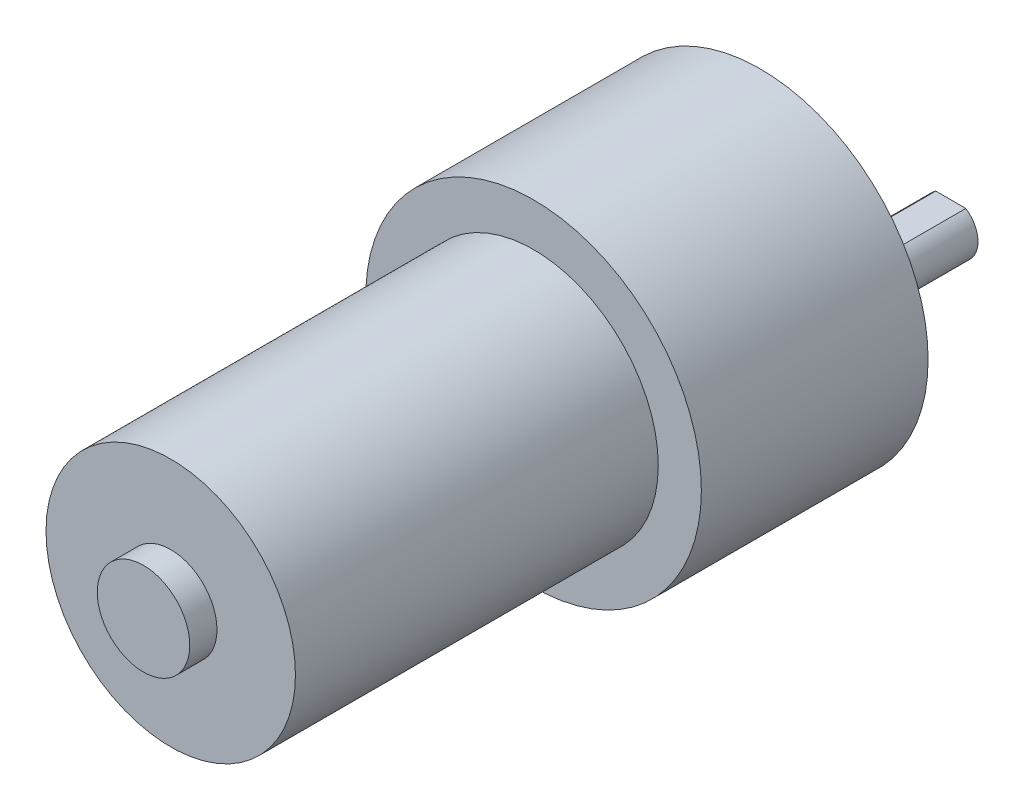
from build123d import *

# Parameters (mm, degrees)
SKETCH_1_R          = 18.5
EXTRUDE_1_DEPTH     = 25
SKETCH_3_R          = 13.75
EXTRUDE_2_DEPTH     = 40
SKETCH_4_R          = 1.5
CUT_EXTRUDE_1_DEPTH = 3
SKETCH_5_R          = 6
EXTRUDE_3_DEPTH     = 6
SKETCH_6_R          = 3
EXTRUDE_4_DEPTH     = 15
CUT_EXTRUDE_2_DEPTH = 12
SKETCH_8_R          = 5.1
EXTRUDE_5_DEPTH     = 3


with BuildPart() as part:
    # ｽｹｯﾁ1 → ﾎﾞｽ - 押し出し1 (new body)
    with BuildSketch(Plane.XY):
        Circle(SKETCH_1_R)
    extrude(amount=EXTRUDE_1_DEPTH)

    # ｽｹｯﾁ3 → ﾎﾞｽ - 押し出し2 (add)
    with BuildSketch(Plane.XY.offset(25)):
        Circle(SKETCH_3_R)
    extrude(amount=EXTRUDE_2_DEPTH)

    # ｽｹｯﾁ4 → ｶｯﾄ - 押し出し1 (cut)
    with BuildSketch(Plane(origin=(0, 0, 0), x_dir=(-1, 0, 0), z_dir=(0, 0, -1))):
        with Locations((-7.75, 13.423393759)):
            Circle(SKETCH_4_R)
        with Locations((-7.75, -13.423393759)):
            Circle(SKETCH_4_R)
        with Locations((15.5, 0)):
            Circle(SKETCH_4_R)
    extrude(amount=-CUT_EXTRUDE_1_DEPTH, mode=Mode.SUBTRACT)

    # ｽｹｯﾁ5 → ﾎﾞｽ - 押し出し3 (add)
    with BuildSketch(Plane(origin=(0, 0, 0), x_dir=(-1, 0, 0), z_dir=(0, 0, -1))):
        with Locations((0, -7)):
            Circle(SKETCH_5_R)
    extrude(amount=EXTRUDE_3_DEPTH)

    # ｽｹｯﾁ6 → ﾎﾞｽ - 押し出し4 (add)
    with BuildSketch(Plane(origin=(0, 0, -6), x_dir=(-1, 0, 0), z_dir=(0, 0, -1))):
        with Locations((0, -7)):
            Circle(SKETCH_6_R)
    extrude(amount=EXTRUDE_4_DEPTH)

    # ｽｹｯﾁ7 → ｶｯﾄ - 押し出し2 (cut)
    with BuildSketch(Plane(origin=(0, 0, -21), x_dir=(-1, 0, 0), z_dir=(0, 0, -1))):
        with BuildLine():
            ThreePointArc((1.658312395, -4.5), (0, -4), (-1.658312395, -4.5))
            Line((-1.658312395, -4.5), (1.658312395, -4.5))
        make_face()
    extrude(amount=-CUT_EXTRUDE_2_DEPTH, mode=Mode.SUBTRACT)

    # ｽｹｯﾁ8 → ﾎﾞｽ - 押し出し5 (add)
    with BuildSketch(Plane.XY.offset(65)):
        Circle(SKETCH_8_R)
    extrude(amount=EXTRUDE_5_DEPTH)


solid = part.part
